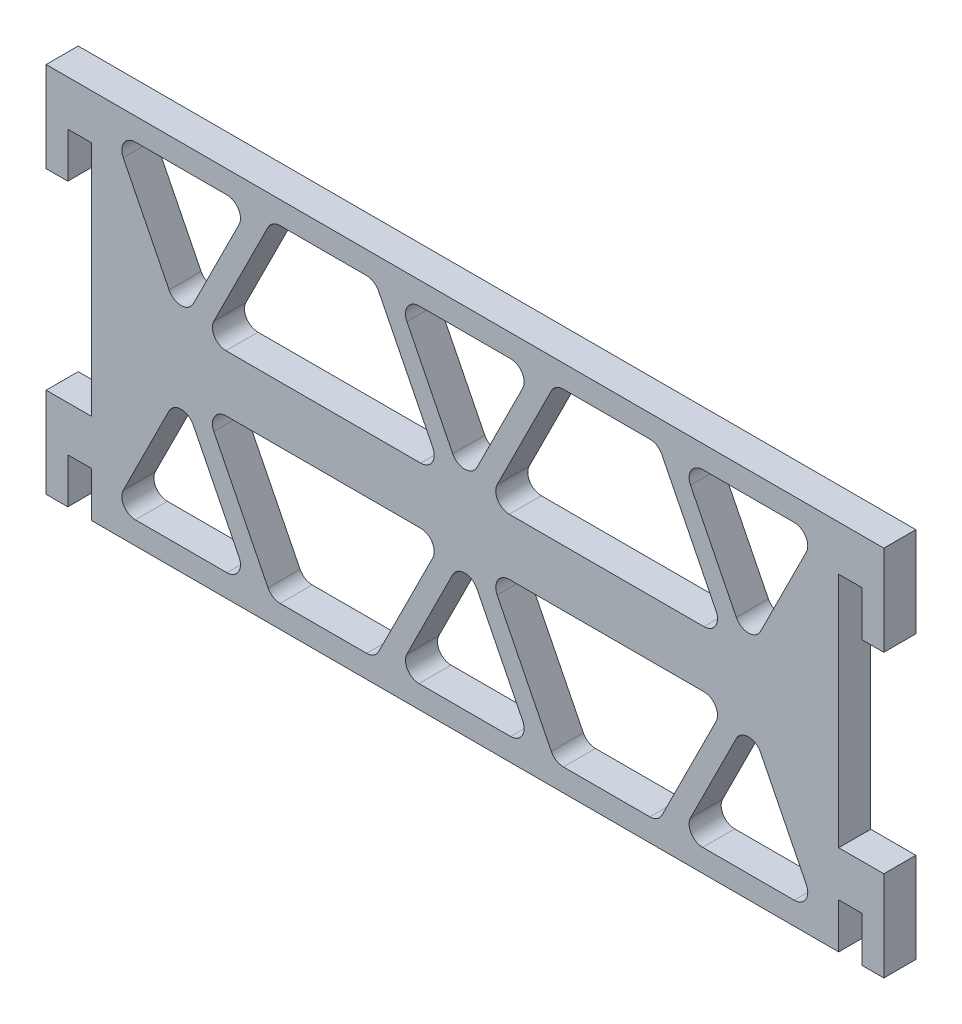
from build123d import *

# Parameters (mm, degrees)
SKETCH1_W            = 105.1814
SKETCH1_H            = 68.320954018
BOSS_EXTRUDE1_DEPTH  = 4.5085
SKETCH2_W            = 105.1814
SKETCH2_H            = 15.933454036
CUT_EXTRUDE1_DEPTH   = 10.795
SKETCH3_W            = 6.35
SKETCH3_H            = 12.7
BOSS_EXTRUDE2_DEPTH  = 4.5085
CUT_EXTRUDE2_DEPTH   = 4.7625
LPATTERN1_COUNT      = 3
LPATTERN1_PITCH      = 39.916133528
CUT_EXTRUDE3_DEPTH   = 4.7625
FILLET2_R            = 1.905
MIRROR3_COPY_1_DEPTH = 4.7625
MIRROR3_COPY_2_DEPTH = 4.7625
MIRROR3_COPY_3_DEPTH = 4.7625
FILLET3_R            = 1.905
SKETCH6_W            = 3.302
SKETCH6_H            = 6.35
CUT_EXTRUDE4_DEPTH   = 6.35


with BuildPart() as part:
    # Sketch1 → Boss-Extrude1 (new body)
    with BuildSketch(Plane.XY):
        Rectangle(SKETCH1_W, SKETCH1_H)
    extrude(amount=BOSS_EXTRUDE1_DEPTH)

    # Sketch2 → Cut-Extrude1 (cut)
    with BuildSketch(Plane.XY.offset(4.5085)):
        with Locations((0, 26.193749991)):
            Rectangle(SKETCH2_W, SKETCH2_H)
    extrude(amount=-CUT_EXTRUDE1_DEPTH, mode=Mode.SUBTRACT)

    # Sketch3 → Boss-Extrude2 (add)
    with BuildSketch(Plane.XY.offset(4.5085)):
        with Locations((-55.7657, -27.810477009)):
            Rectangle(SKETCH3_W, SKETCH3_H)
        with Locations((-55.7657, 11.877022991)):
            Rectangle(SKETCH3_W, SKETCH3_H)
    boss_extrude2 = extrude(amount=-BOSS_EXTRUDE2_DEPTH)

    # Mirror1: Boss-Extrude2 across plane
    add(boss_extrude2.mirror(Plane(origin=(0, 0, 0), x_dir=(0, 0, 1), z_dir=(1, 0, 0))))

    # Sketch4 → Cut-Extrude2 (cut)
    with BuildSketch(Plane(origin=(0, 0, 0), x_dir=(-1, 0, 0), z_dir=(0, 0, -1))):
        Polygon((-49.4157, 15.052022991), (-30.3657, 15.052022991), (-39.8907, -3.997977009), align=None)
    cut_extrude2 = extrude(amount=-CUT_EXTRUDE2_DEPTH, mode=Mode.SUBTRACT)

    # LPattern1: Cut-Extrude2 ×3
    with Locations(*[(-i * LPATTERN1_PITCH, 0, 0) for i in range(1, LPATTERN1_COUNT)]):
        add(cut_extrude2, mode=Mode.SUBTRACT)

    # Sketch5 → Cut-Extrude3 (cut)
    with BuildSketch(Plane(origin=(0, 0, 0), x_dir=(-1, 0, 0), z_dir=(0, 0, -1))):
        Polygon((-27.1907, 15.052022991), (-12.674566472, 15.052022991), (-3.149566472, -3.997977009), (-36.7157, -3.997977009), align=None)
    cut_extrude3 = extrude(amount=-CUT_EXTRUDE3_DEPTH, mode=Mode.SUBTRACT)

    # Mirror2: Cut-Extrude3 across plane
    add(cut_extrude3.mirror(Plane(origin=(0, 0, 0), x_dir=(0, 0, 1), z_dir=(1, 0, 0))), mode=Mode.SUBTRACT)

    # Fillet2
    fillet2_edges = [part.edges().sort_by_distance(p)[0] for p in [
        (-0.025433528, -3.997977009, 2.25425),
        (9.499566472, 15.052022991, 2.25425),
        (-9.550433528, 15.052022991, 2.25425),
        (-30.416567056, 15.052022991, 2.25425),
        (-39.941567056, -3.997977009, 2.25425),
        (-49.466567056, 15.052022991, 2.25425),
        (39.8907, -3.997977009, 2.25425),
        (49.4157, 15.052022991, 2.25425),
        (30.3657, 15.052022991, 2.25425),
    ]]
    fillet(fillet2_edges, radius=FILLET2_R)

    # Mirror3: Cut-Extrude2, Cut-Extrude3 across plane
    add(cut_extrude2.mirror(Plane.ZX.offset(-7.966727018)), mode=Mode.SUBTRACT)
    add(cut_extrude3.mirror(Plane.ZX.offset(-7.966727018)), mode=Mode.SUBTRACT)

    # Mirror3 copy 1 sketch → Mirror3 copy 1 (cut)
    with BuildSketch(Plane(origin=(-39.916133528, -15.933454036, 0), x_dir=(-1, 0, 0), z_dir=(0, 0, -1))):
        Polygon((-49.4157, -15.052022991), (-30.3657, -15.052022991), (-39.8907, 3.997977009), align=None)
    extrude(amount=-MIRROR3_COPY_1_DEPTH, mode=Mode.SUBTRACT)

    # Mirror3 copy 2 sketch → Mirror3 copy 2 (cut)
    with BuildSketch(Plane(origin=(-79.832267056, -15.933454036, 0), x_dir=(-1, 0, 0), z_dir=(0, 0, -1))):
        Polygon((-49.4157, -15.052022991), (-30.3657, -15.052022991), (-39.8907, 3.997977009), align=None)
    extrude(amount=-MIRROR3_COPY_2_DEPTH, mode=Mode.SUBTRACT)

    # Mirror3 copy 3 sketch → Mirror3 copy 3 (cut)
    with BuildSketch(Plane(origin=(0, -15.933454036, 0), x_dir=(1, 0, 0), z_dir=(0, 0, -1))):
        Polygon((-27.1907, 15.052022991), (-12.674566472, 15.052022991), (-3.149566472, -3.997977009), (-36.7157, -3.997977009), align=None)
    extrude(amount=-MIRROR3_COPY_3_DEPTH, mode=Mode.SUBTRACT)

    # Fillet3
    fillet3_edges = [part.edges().sort_by_distance(p)[0] for p in [
        (36.7157, -3.997977009, 2.25425),
        (27.1907, 15.052022991, 2.25425),
        (12.674566472, 15.052022991, 2.25425),
        (3.149566472, -3.997977009, 2.25425),
        (-27.1907, 15.052022991, 2.25425),
        (-36.7157, -3.997977009, 2.25425),
        (-3.149566472, -3.997977009, 2.25425),
        (-12.674566472, 15.052022991, 2.25425),
        (49.4157, -30.985477027, 2.25425),
        (39.8907, -11.935477027, 2.25425),
        (30.3657, -30.985477027, 2.25425),
        (9.499566472, -30.985477027, 2.25425),
        (-0.025433528, -11.935477027, 2.25425),
        (-9.550433528, -30.985477027, 2.25425),
        (-30.416567056, -30.985477027, 2.25425),
        (-39.941567056, -11.935477027, 2.25425),
        (-49.466567056, -30.985477027, 2.25425),
        (-36.7157, -11.935477027, 2.25425),
        (-27.1907, -30.985477027, 2.25425),
        (-12.674566472, -30.985477027, 2.25425),
        (-3.149566472, -11.935477027, 2.25425),
        (27.1907, -30.985477027, 2.25425),
        (36.7157, -11.935477027, 2.25425),
        (3.149566472, -11.935477027, 2.25425),
        (12.674566472, -30.985477027, 2.25425),
    ]]
    fillet(fillet3_edges, radius=FILLET3_R)

    # Sketch6 → Cut-Extrude4 (cut)
    with BuildSketch(Plane(origin=(0, 0, 0), x_dir=(-1, 0, 0), z_dir=(0, 0, -1))):
        with Locations((-54.2417, 8.702022991)):
            Rectangle(SKETCH6_W, SKETCH6_H)
        with Locations((54.2417, 8.702022991)):
            Rectangle(SKETCH6_W, SKETCH6_H)
        with Locations((-54.2417, -30.985477009)):
            Rectangle(SKETCH6_W, SKETCH6_H)
        with Locations((54.2417, -30.985477009)):
            Rectangle(SKETCH6_W, SKETCH6_H)
    extrude(amount=-CUT_EXTRUDE4_DEPTH, mode=Mode.SUBTRACT)


solid = part.part
